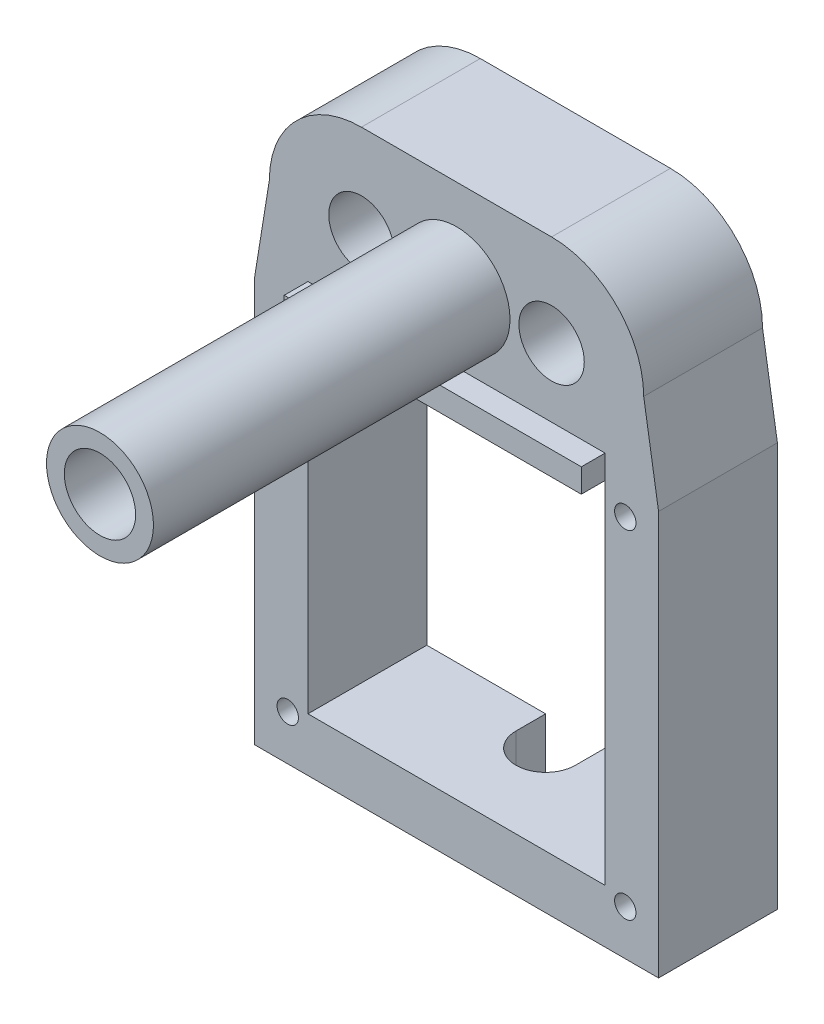
from build123d import *

# Parameters (mm, degrees)
SKETCH1_R           = 2.75
BOSS_EXTRUDE1_DEPTH = 10
SKETCH2_R           = 3
CUT_EXTRUDE1_DEPTH  = 15
SKETCH3_R           = 4.5
SKETCH3_R_2         = 3
BOSS_EXTRUDE2_DEPTH = 30
BOSS_EXTRUDE4_DEPTH = 10
CUT_EXTRUDE2_DEPTH  = 10
SKETCH7_W           = 25
SKETCH7_H           = 2
BOSS_EXTRUDE6_DEPTH = 2
SKETCH8_R           = 0.9
CUT_EXTRUDE3_DEPTH  = 19


with BuildPart() as part:
    # Sketch1 → Boss-Extrude1 (new body)
    with BuildSketch(Plane.XY):
        with BuildLine():
            Line((8, 7.75), (-8, 7.75))
            ThreePointArc((-8, 7.75), (-15.75, 0), (-8, -7.75))
            Line((-8, -7.75), (8, -7.75))
            ThreePointArc((8, -7.75), (15.75, 0), (8, 7.75))
        make_face()
        with Locations((-8, 0)):
            Circle(SKETCH1_R, mode=Mode.SUBTRACT)
        with Locations((8, 0)):
            Circle(SKETCH1_R, mode=Mode.SUBTRACT)
    extrude(amount=BOSS_EXTRUDE1_DEPTH)

    # Sketch2 → Cut-Extrude1 (cut)
    with BuildSketch(Plane.XY.offset(10)):
        Circle(SKETCH2_R)
    extrude(amount=-CUT_EXTRUDE1_DEPTH, mode=Mode.SUBTRACT)

    # Sketch3 → Boss-Extrude2 (add)
    with BuildSketch(Plane.XY.offset(10)):
        Circle(SKETCH3_R)
        Circle(SKETCH3_R_2, mode=Mode.SUBTRACT)
    extrude(amount=BOSS_EXTRUDE2_DEPTH)

    # Sketch5 → Boss-Extrude4 (add)
    with BuildSketch(Plane.XY):
        Polygon((-12.5, -7.75), (-17, -7.75), (-17, -41.75), (17, -41.75), (17, -7.75), (12.5, -7.75), (12.5, -12.25), (12.5, -37.25), (-12.5, -37.25), (-12.5, -12.25), align=None)
        with BuildLine():
            ThreePointArc((-8, -7.75), (-13.480077554, -5.480077554), (-15.75, 0))
            Line((-15.75, 0), (-17, -7.75))
            Line((-17, -7.75), (-12.5, -7.75))
            Line((-12.5, -7.75), (-8, -7.75))
        make_face()
        with BuildLine():
            ThreePointArc((15.75, 0), (13.480077554, -5.480077554), (8, -7.75))
            Line((8, -7.75), (12.5, -7.75))
            Line((12.5, -7.75), (17, -7.75))
            Line((17, -7.75), (15.75, 0))
        make_face()
    extrude(amount=BOSS_EXTRUDE4_DEPTH)

    # Sketch6 → Cut-Extrude2 (cut)
    with BuildSketch(Plane.XZ.offset(41.75)):
        with BuildLine():
            Line((-2.5, 0), (2.5, 0))
            Line((2.5, 0), (2.5, 2.5))
            ThreePointArc((2.5, 2.5), (0, 5), (-2.5, 2.5))
            Line((-2.5, 2.5), (-2.5, 0))
        make_face()
    extrude(amount=-CUT_EXTRUDE2_DEPTH, mode=Mode.SUBTRACT)

    # Sketch7 → Boss-Extrude6 (add)
    with BuildSketch(Plane.XY.offset(10)):
        with Locations((0, -6.75)):
            Rectangle(SKETCH7_W, SKETCH7_H)
    extrude(amount=BOSS_EXTRUDE6_DEPTH)

    # Sketch8 → Cut-Extrude3 (cut)
    with BuildSketch(Plane.XY.offset(10)):
        with Locations((-14.2, -9.55)):
            Circle(SKETCH8_R)
        with Locations((14.2, -9.55)):
            Circle(SKETCH8_R)
        with Locations((14.2, -37.95)):
            Circle(SKETCH8_R)
        with Locations((-14.2, -37.95)):
            Circle(SKETCH8_R)
    extrude(amount=-CUT_EXTRUDE3_DEPTH, mode=Mode.SUBTRACT)


solid = part.part
